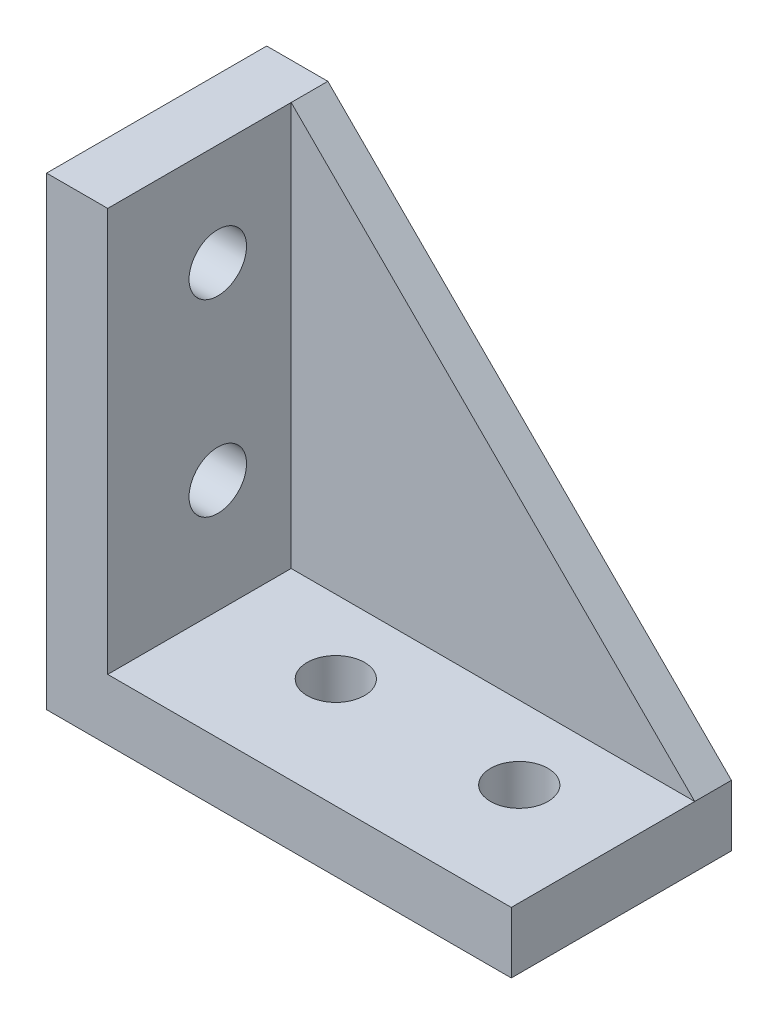
from build123d import *

# Parameters (mm, degrees)
EXTRUDE_1_DEPTH          = 18
GUSSET_1_THICKNESS       = 3
SKETCH_4_R               = 2.35
CUT_EXTRUDE_1_DEPTH      = 12
CUT_EXTRUDE_1_DEPTH_BACK = 13
SKETCH_5_R               = 2.35
CUT_EXTRUDE_2_DEPTH      = 15
CUT_EXTRUDE_2_DEPTH_BACK = 12


with BuildPart() as part:
    # 草图1 → 凸台-拉伸1 (new body)
    with BuildSketch(Plane.XY):
        Polygon((0, 38), (0, 0), (38, 0), (38, 5), (5, 5), (5, 38), align=None)
    extrude(amount=EXTRUDE_1_DEPTH)

    # 草图4 → 切除-拉伸1 (cut, two sides)
    with BuildSketch(Plane(origin=(5, 0, 0), x_dir=(0, 0, -1), z_dir=(1, 0, 0))) as cut_extrude_1_sk:
        with Locations(Location((-9, 29.65, 0), (0, 0, 180))):
            Circle(SKETCH_4_R)
        with Locations(Location((-9, 14.25, 0), (0, 0, 180))):
            Circle(SKETCH_4_R)
    extrude(amount=CUT_EXTRUDE_1_DEPTH, mode=Mode.SUBTRACT)
    extrude(cut_extrude_1_sk.sketch, amount=-CUT_EXTRUDE_1_DEPTH_BACK, mode=Mode.SUBTRACT)

    # 草图5 → 切除-拉伸2 (cut, two sides)
    with BuildSketch(Plane(origin=(0, 5, 0), x_dir=(1, 0, 0), z_dir=(0, 1, 0))) as cut_extrude_2_sk:
        with Locations(Location((29.65, -9, 0), (0, 0, 90))):
            Circle(SKETCH_5_R)
        with Locations(Location((14.65, -9, 0), (0, 0, 90))):
            Circle(SKETCH_5_R)
    extrude(amount=CUT_EXTRUDE_2_DEPTH, mode=Mode.SUBTRACT)
    extrude(cut_extrude_2_sk.sketch, amount=-CUT_EXTRUDE_2_DEPTH_BACK, mode=Mode.SUBTRACT)


with BuildPart() as body_2:
    # Gusset 1: a gusset: a plate 3.0 thick in the corner of two members, its outline drawn in place
    gusset_1_outline = Wire([Line((5, 5, 0), (5, 38, 0)), Line((5, 38, 0), (38, 5, 0)), Line((38, 5, 0), (5, 5, 0))])
    add(extrude(Face(gusset_1_outline), amount=GUSSET_1_THICKNESS, dir=(0, 0, 1)))


solid = Compound([part.part, body_2.part])
